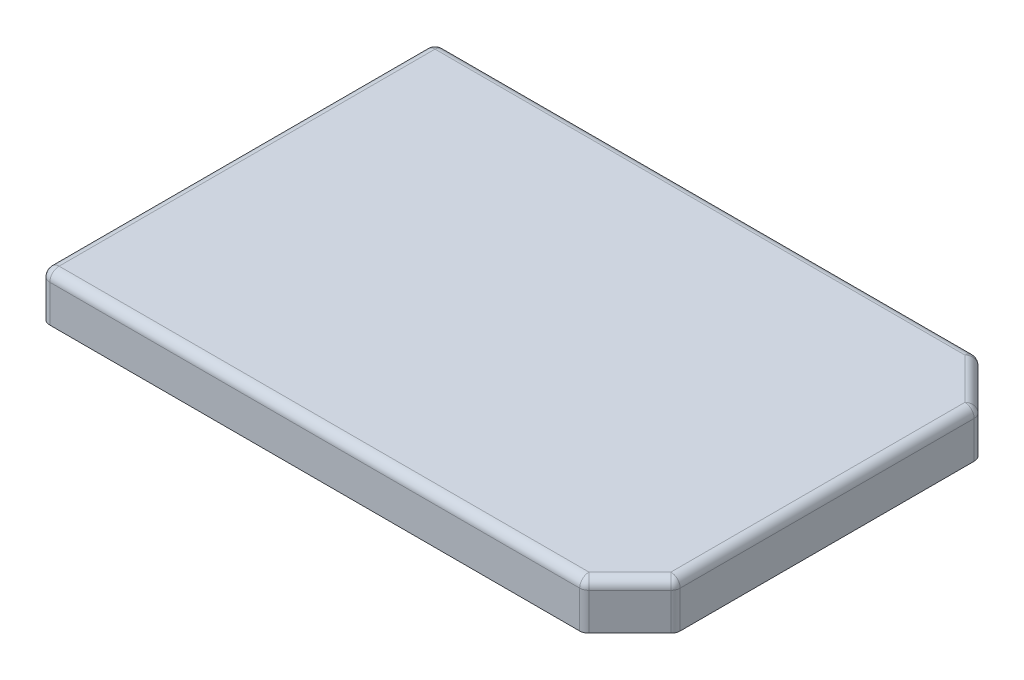
from build123d import *

# Parameters (mm, degrees)
SKETCH1_W           = 127
SKETCH1_H           = 85
BOSS_EXTRUDE1_DEPTH = 10
CHAMFER1_SIZE       = 10
FILLET1_R           = 2
FILLET2_R           = 2
CUT_EXTRUDE1_DEPTH  = 7.3


with BuildPart() as part:
    # Sketch1 → Boss-Extrude1 (new body)
    with BuildSketch(Plane(origin=(0, 0, 0), x_dir=(1, 0, 0), z_dir=(0, 1, 0))):
        with Locations((63.5, -42.5)):
            Rectangle(SKETCH1_W, SKETCH1_H)
    extrude(amount=BOSS_EXTRUDE1_DEPTH)

    # Chamfer1
    chamfer1_edges = [part.edges().sort_by_distance(p)[0] for p in [
        (127, 5, 0),
        (127, 5, 85),
    ]]
    chamfer(chamfer1_edges, length=CHAMFER1_SIZE)

    # Fillet1
    fillet1_edges = [part.edges().sort_by_distance(p)[0] for p in [
        (127, 5, 10),
        (127, 5, 75),
        (117, 5, 85),
        (117, 5, 0),
        (0, 5, 0),
        (0, 5, 85),
    ]]
    fillet(fillet1_edges, radius=FILLET1_R)

    # Fillet2
    fillet2_edges = [part.edges().sort_by_distance(p)[0] for p in [
        (127, 10, 42.5),
        (122, 10, 80),
        (59.085786438, 10, 85),
        (122, 10, 5),
        (59.085786438, 10, 0),
        (0, 10, 42.5),
        (126.847759065, 10, 10.06306026),
        (116.93693974, 10, 0.152240935),
        (0.585786438, 10, 0.585786438),
        (0.585786438, 10, 84.414213562),
        (116.93693974, 10, 84.847759065),
        (126.847759065, 10, 74.93693974),
    ]]
    fillet(fillet2_edges, radius=FILLET2_R)

    # Sketch2 → Cut-Extrude1 (cut)
    with BuildSketch(Plane.XZ):
        Polygon((1.25, 83.75), (115.75, 83.75), (125.75, 73.75), (125.75, 11.25), (115.75, 1.25), (1.25, 1.25), align=None)
    extrude(amount=-CUT_EXTRUDE1_DEPTH, mode=Mode.SUBTRACT)


solid = part.part
